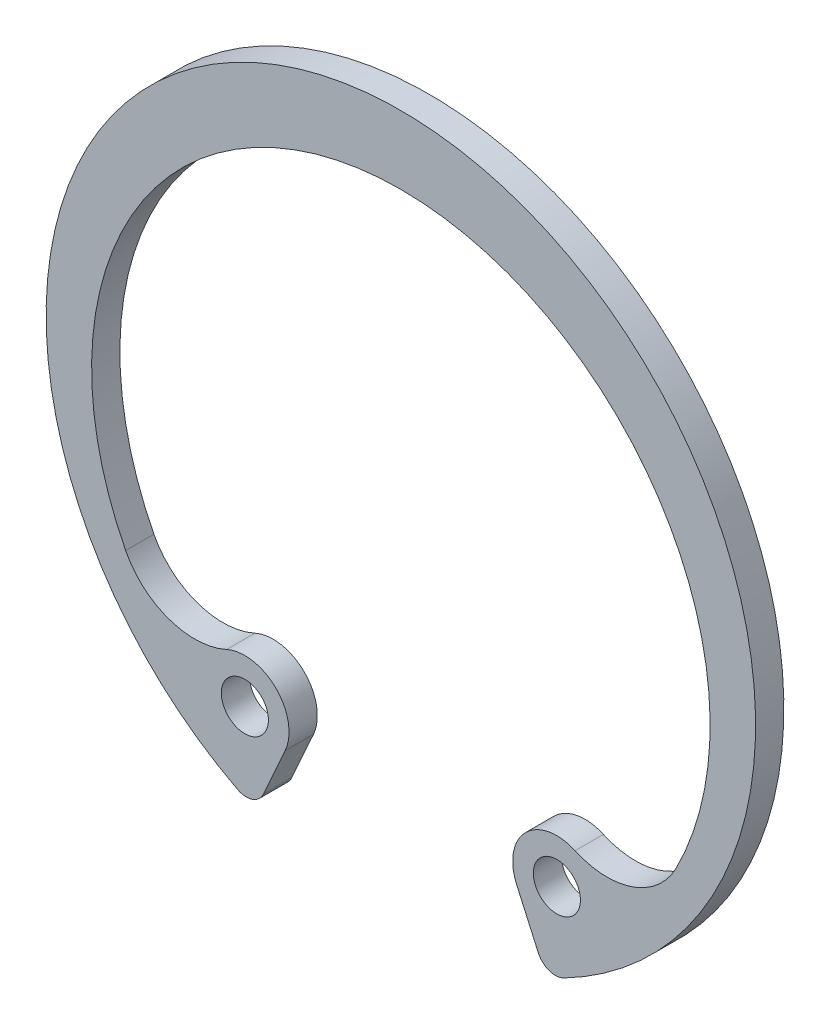
from build123d import *

# Parameters (mm, degrees)
SKETCH3_R                = 1
BOSS_EXTRUDE1_DEPTH      = 0.6
BOSS_EXTRUDE1_DEPTH_BACK = 0.6
FILLET1_R                = 0.79375


with BuildPart() as part:
    # Sketch3 → Boss-Extrude1 (new body, two sides)
    with BuildSketch(Plane.XY) as boss_extrude1_sk:
        with BuildLine():
            Line((-4.908529162, -10.927320873), (-6.166829268, -13.728536585))
            ThreePointArc((-6.166829268, -13.728536585), (0, 15.05), (6.166829268, -13.728536585))
            Line((6.166829268, -13.728536585), (4.908529162, -10.927320873))
            ThreePointArc((4.908529162, -10.927320873), (5.295325192, -8.830951414), (7.392997394, -8.451283915))
            ThreePointArc((7.392997394, -8.451283915), (9.833420056, -8.560996803), (11.675794705, -6.956828689))
            ThreePointArc((11.675794705, -6.956828689), (0, 12.15), (-11.675794705, -6.956828689))
            ThreePointArc((-11.675794705, -6.956828689), (-9.833420056, -8.560996803), (-7.392997394, -8.451283915))
            ThreePointArc((-7.392997394, -8.451283915), (-5.295325192, -8.830951414), (-4.908529162, -10.927320873))
        make_face()
        with Locations((-6.618895016, -10.15902819)):
            Circle(SKETCH3_R, mode=Mode.SUBTRACT)
        with Locations((6.618895016, -10.15902819)):
            Circle(SKETCH3_R, mode=Mode.SUBTRACT)
    extrude(amount=BOSS_EXTRUDE1_DEPTH)
    extrude(boss_extrude1_sk.sketch, amount=-BOSS_EXTRUDE1_DEPTH_BACK)

    # Fillet1
    fillet1_edges = [part.edges().sort_by_distance(p)[0] for p in [
        (6.166829268, -13.728536585, 0),
        (-6.166829268, -13.728536585, 0),
    ]]
    fillet(fillet1_edges, radius=FILLET1_R)


solid = part.part
